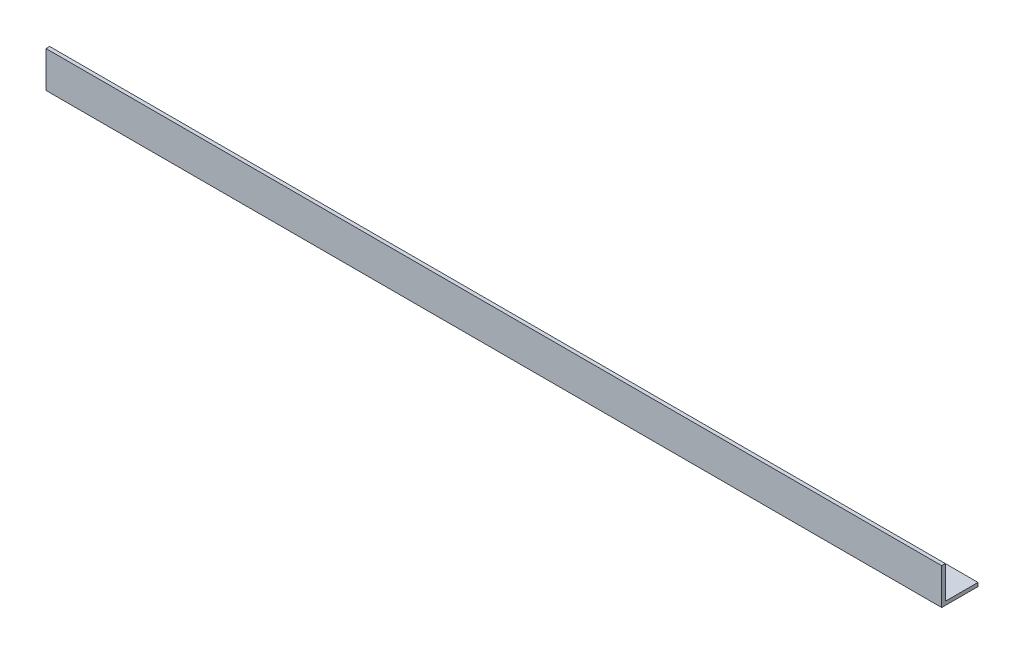
from build123d import *

# Parameters (mm, degrees)
EXTRUDE_1_DEPTH = 370


with BuildPart() as part:
    # Эскиз1 → Бобышка-Вытянуть1 (new body)
    with BuildSketch(Plane(origin=(0, 0, 0), x_dir=(0, 0, -1), z_dir=(1, 0, 0))):
        Polygon((0, 0), (0, 15), (1.5, 15), (1.5, 1.5), (15, 1.5), (15, 0), align=None)
    extrude(amount=EXTRUDE_1_DEPTH)


solid = part.part
